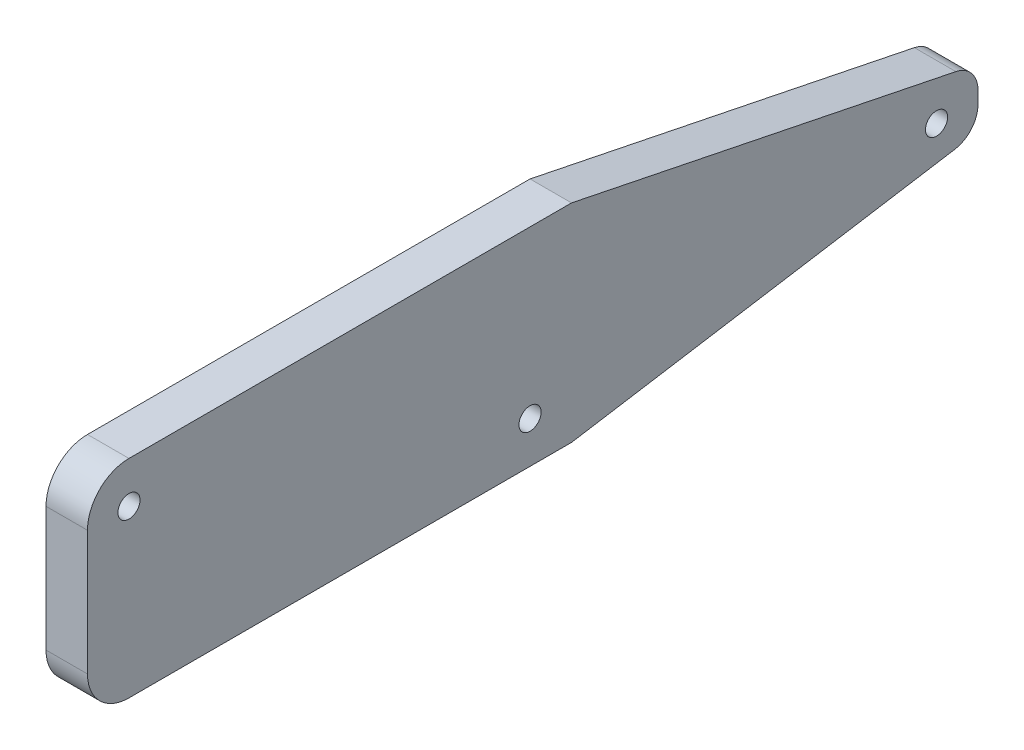
from build123d import *

# Parameters (mm, degrees)
ESBO_O1_R                = 0.8
RESSALTO_EXTRUS_O1_DEPTH = 3
FILETE1_R                = 3
FILETE2_R                = 3


with BuildPart() as part:
    # Esboço1 → Ressalto-extrusão1 (new body)
    with BuildSketch(Plane(origin=(0, 0, 0), x_dir=(0, 0, -1), z_dir=(1, 0, 0))):
        with BuildLine():
            Line((-26.317877539, 0), (-26.317877539, 7.5))
            Line((-26.317877539, 7.5), (8.682122461, 7.5))
            Line((8.682122461, 7.5), (36.475999374, 1.826598632))
            ThreePointArc((36.475999374, 1.826598632), (37.625192713, 1.131917902), (38.075999374, -0.132993162))
            Line((38.075999374, -0.132993162), (38.075999374, -1.030306154))
            ThreePointArc((38.075999374, -1.030306154), (37.599230732, -2.326364112), (36.396233145, -3.004502277))
            Line((36.396233145, -3.004502277), (8.682122461, -7.5))
            Line((8.682122461, -7.5), (-26.317877539, -7.5))
            Line((-26.317877539, -7.5), (-26.317877539, 0))
        make_face()
        with Locations((-23.317877539, 4.5)):
            Circle(ESBO_O1_R, mode=Mode.SUBTRACT)
        with Locations((5.682122461, -4.5)):
            Circle(ESBO_O1_R, mode=Mode.SUBTRACT)
        with Locations((35.075999374, -0.719592125)):
            Circle(ESBO_O1_R, mode=Mode.SUBTRACT)
    extrude(amount=RESSALTO_EXTRUS_O1_DEPTH)

    # Filete1
    filete1_edges = [part.edges().sort_by_distance(p)[0] for p in [
        (1.5, -7.5, 26.317877539),
    ]]
    fillet(filete1_edges, radius=FILETE1_R)

    # Filete2
    filete2_edges = [part.edges().sort_by_distance(p)[0] for p in [
        (1.5, 7.5, 26.317877539),
    ]]
    fillet(filete2_edges, radius=FILETE2_R)


solid = part.part
